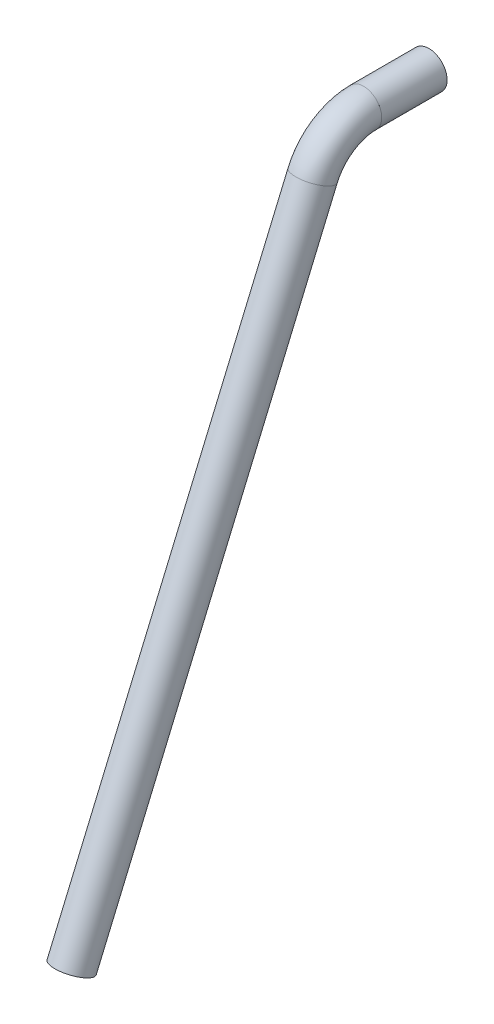
from build123d import *

# Parameters (mm, degrees)
SKETCH1_ON_SEGMENT_1_R       = 16.7005
SKETCH1_ON_SEGMENT_1_R_2     = 13.3223
MIEMBRO_ESTRUCTURAL1_DEPTH   = 60
SKETCH1_ON_SEGMENT_2_R       = 16.7005
SKETCH1_ON_SEGMENT_2_R_2     = 13.3223
MIEMBRO_ESTRUCTURAL1_2_ANGLE = 66.911890628
SKETCH1_R                    = 16.7005
SKETCH1_R_2                  = 13.3223
MIEMBRO_ESTRUCTURAL1_3_DEPTH = 563.925789853


with BuildPart() as part:
    # Sketch1 on segment 1 (carried to segment 1) → Miembro estructural1 (new body)
    with BuildSketch(Plane(origin=(0, 261.82519321, -140.734827912), x_dir=(0, -1, 0), z_dir=(0, 0, 1))):
        Circle(SKETCH1_ON_SEGMENT_1_R)
        Circle(SKETCH1_ON_SEGMENT_1_R_2, mode=Mode.SUBTRACT)
    extrude(amount=MIEMBRO_ESTRUCTURAL1_DEPTH)


with BuildPart() as body_2:
    # Sketch1 on segment 2 (carried to the start of arc 2) → Miembro estructural1 2 (revolve)
    with BuildSketch(Plane(origin=(0, 261.82519321, -80.734827912), x_dir=(0, -1, 0), z_dir=(0, 0, 1))):
        Circle(SKETCH1_ON_SEGMENT_2_R)
        Circle(SKETCH1_ON_SEGMENT_2_R_2, mode=Mode.SUBTRACT)
    revolve(axis=Axis((0, 211.02519321, -80.734827912), (1, 0, 0)), revolution_arc=MIEMBRO_ESTRUCTURAL1_2_ANGLE)


with BuildPart() as body_3:
    # Sketch1 → Miembro estructural1 3 (new body)
    with BuildSketch(Plane(origin=(0, 230.946221036, -34.003760619), x_dir=(0, -0.3921462170451, -0.9199028994721221), z_dir=(0, -0.9199028994721222, 0.3921462170451001))):
        Circle(SKETCH1_R)
        Circle(SKETCH1_R_2, mode=Mode.SUBTRACT)
    extrude(amount=MIEMBRO_ESTRUCTURAL1_3_DEPTH)


solid = Compound([part.part, body_2.part, body_3.part])
